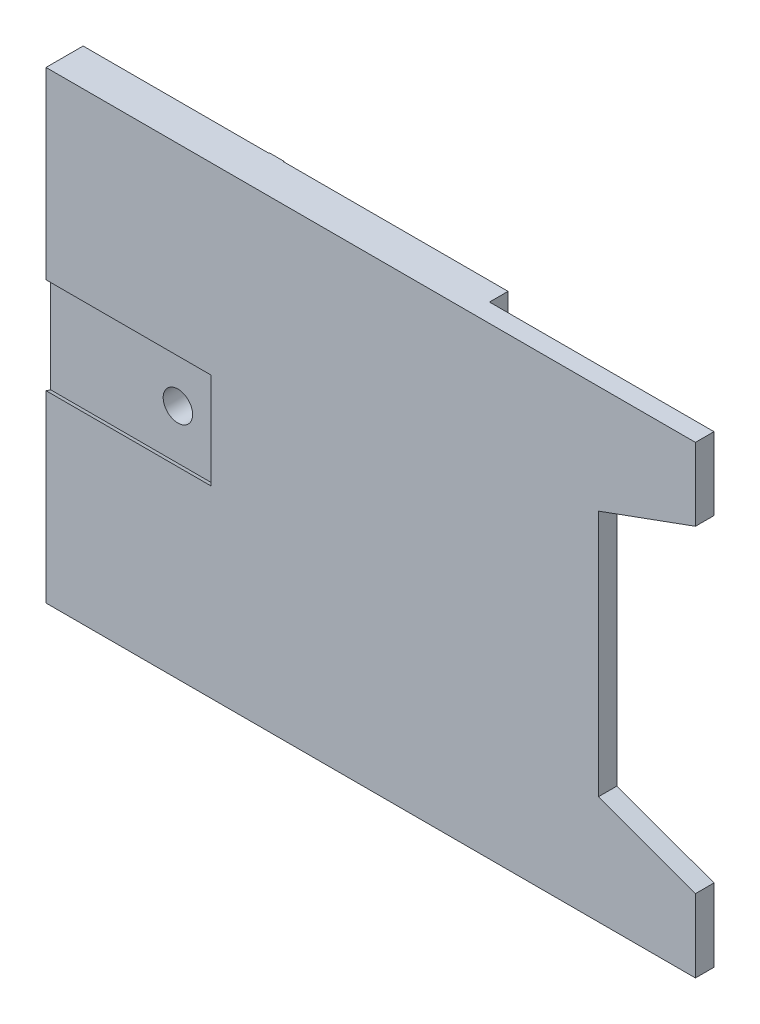
from build123d import *

# Parameters (mm, degrees)
BOSS_EXTRUDE1_DEPTH = 4
SKETCH3_W           = 24.197009966
SKETCH3_H           = 2
CUT_EXTRUDE1_DEPTH  = 51
SKETCH5_W           = 4
SKETCH5_H           = 50
BOSS_EXTRUDE2_DEPTH = 20
CUT_EXTRUDE2_DEPTH  = 17.78
SKETCH7_R           = 1.5875
CUT_EXTRUDE3_DEPTH  = 5
SKETCH8_W           = 1.605980069
SKETCH8_H           = 2.54
BOSS_EXTRUDE3_DEPTH = 4.064


with BuildPart() as part:
    # Sketch2 → Boss-Extrude1 (new body)
    with BuildSketch(Plane.XY):
        Polygon((50, 42.164), (50, 50), (1.605980069, 50), (1.605980069, 47.46), (0, 47.46), (0, 0), (50, 0), (50, 7.874), (39.535978332, 11.684), (39.535978332, 38.354), align=None)
    extrude(amount=BOSS_EXTRUDE1_DEPTH)

    # Sketch3 → Cut-Extrude1 (cut, through all)
    with BuildSketch(Plane(origin=(0, 50, 0), x_dir=(1, 0, 0), z_dir=(0, 1, 0))):
        with Locations((37.901495017, -1)):
            Rectangle(SKETCH3_W, SKETCH3_H)
    extrude(amount=-CUT_EXTRUDE1_DEPTH, mode=Mode.SUBTRACT)

    # Sketch5 → Boss-Extrude2 (add)
    with BuildSketch(Plane.ZY):
        with Locations((2, 25)):
            Rectangle(SKETCH5_W, SKETCH5_H)
    extrude(amount=BOSS_EXTRUDE2_DEPTH)

    # Sketch6 → Cut-Extrude2 (cut)
    with BuildSketch(Plane.ZY.offset(20)):
        with BuildLine():
            Line((3.5, 19.656649926), (3.5, 30.343350074))
            ThreePointArc((3.5, 30.343350074), (3.751975341, 30.266115496), (4, 30.177005892))
            Line((4, 30.177005892), (4, 19.822994108))
            ThreePointArc((4, 19.822994108), (3.751975341, 19.733884504), (3.5, 19.656649926))
        make_face()
        with BuildLine():
            Line((0.5, 19.656649926), (0.5, 30.343350074))
            ThreePointArc((0.5, 30.343350074), (0.248024659, 30.266115496), (0, 30.177005892))
            Line((0, 30.177005892), (0, 19.822994108))
            ThreePointArc((0, 19.822994108), (0.248024659, 19.733884504), (0.5, 19.656649926))
        make_face()
    extrude(amount=-CUT_EXTRUDE2_DEPTH, mode=Mode.SUBTRACT)

    # Sketch7 → Cut-Extrude3 (cut, through all)
    with BuildSketch(Plane(origin=(0, 0, 0), x_dir=(-1, 0, 0), z_dir=(0, 0, -1))):
        with Locations((6.284, 25)):
            Circle(SKETCH7_R)
    extrude(amount=-CUT_EXTRUDE3_DEPTH, mode=Mode.SUBTRACT)

    # Sketch8 → Boss-Extrude3 (add)
    with BuildSketch(Plane.XY.offset(4)):
        with Locations((0.802990035, 48.73)):
            Rectangle(SKETCH8_W, SKETCH8_H)
    extrude(amount=-BOSS_EXTRUDE3_DEPTH)


solid = part.part
